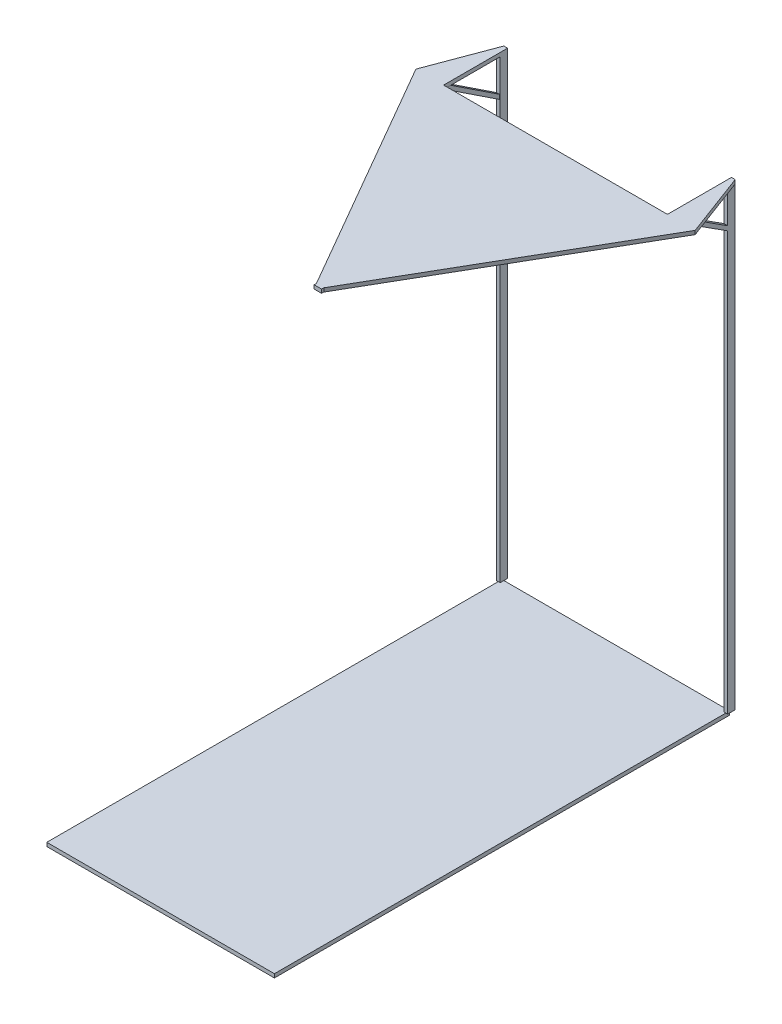
from build123d import *

# Parameters (mm, degrees)
SKETCH2_W           = 304.8
SKETCH2_H           = 609.6
BOSS_EXTRUDE1_DEPTH = 5
SKETCH3_W           = 10
SKETCH3_H           = 610
EXTRUDE_THIN1_DEPTH = 2.5
SKETCH4_W           = 10
SKETCH4_H           = 610
EXTRUDE_THIN2_DEPTH = 2.5
BOSS_EXTRUDE2_DEPTH = 5
EXTRUDE_THIN3_DEPTH = 4
EXTRUDE_THIN5_DEPTH = 5
SKETCH12_W          = 309.8
SKETCH12_H          = 215.656941329
CUT_EXTRUDE1_DEPTH  = 615


with BuildPart() as part:
    # Sketch2 → Boss-Extrude1 (new body)
    with BuildSketch(Plane(origin=(0, 0, 0), x_dir=(1, 0, 0), z_dir=(0, 1, 0))):
        Rectangle(SKETCH2_W, SKETCH2_H)
    extrude(amount=BOSS_EXTRUDE1_DEPTH)

    # Sketch3 → Extrude-Thin1 (add, symmetric)
    with BuildSketch(Plane(origin=(152.4, 0, 0), x_dir=(0, 0, -1), z_dir=(1, 0, 0))):
        with Locations((-304.8, 310)):
            Rectangle(SKETCH3_W, SKETCH3_H)
        with Locations((304.8, 310)):
            Rectangle(SKETCH3_W, SKETCH3_H)
    extrude(amount=EXTRUDE_THIN1_DEPTH, both=True)

    # Sketch4 → Extrude-Thin2 (add, symmetric)
    with BuildSketch(Plane.ZY.offset(152.4)):
        with Locations((-304.8, 310)):
            Rectangle(SKETCH4_W, SKETCH4_H)
        with Locations((304.8, 310)):
            Rectangle(SKETCH4_W, SKETCH4_H)
    extrude(amount=EXTRUDE_THIN2_DEPTH, both=True)

    # Sketch5 → Boss-Extrude2 (add)
    with BuildSketch(Plane(origin=(0, 615, 0), x_dir=(1, 0, 0), z_dir=(0, 1, 0))):
        Polygon((154.9, -309.8), (-154.9, -309.8), (-154.9, -299.8), (-5, -299.8), (-5, -99.8), (-5, -91.133474836), (-187, 224.099772141), (-154.9, 309.8), (-149.9, 309.8), (-149.9, 224.099772141), (149.9, 224.099772141), (149.9, 309.8), (154.9, 309.8), (187, 224.099772141), (5, -91.133474836), (5, -104.787457748), (5, -299.8), (154.9, -299.8), align=None)
    extrude(amount=BOSS_EXTRUDE2_DEPTH)

    # Sketch6 → Extrude-Thin3 (add)
    with BuildSketch(Plane.ZY.offset(154.9)):
        Polygon((-224.099772141, 615), (-299.8, 565), (-302.555663937, 569.172087759), (-226.855436078, 619.172087759), align=None)
    extrude(amount=-EXTRUDE_THIN3_DEPTH)

    # Sketch11 → Extrude-Thin5 (add)
    with BuildSketch(Plane(origin=(154.9, 0, 0), x_dir=(0, 0, -1), z_dir=(1, 0, 0))):
        Polygon((224.099772141, 620), (309.8, 565), (307.099444062, 560.792031651), (221.399216204, 615.792031651), align=None)
    extrude(amount=-EXTRUDE_THIN5_DEPTH)

    # Sketch12 → Cut-Extrude1 (cut)
    with BuildSketch(Plane(origin=(0, 620, 0), x_dir=(1, 0, 0), z_dir=(0, 1, 0))):
        with Locations((0, -201.971529336)):
            Rectangle(SKETCH12_W, SKETCH12_H)
    extrude(amount=-CUT_EXTRUDE1_DEPTH, mode=Mode.SUBTRACT)


solid = part.part
